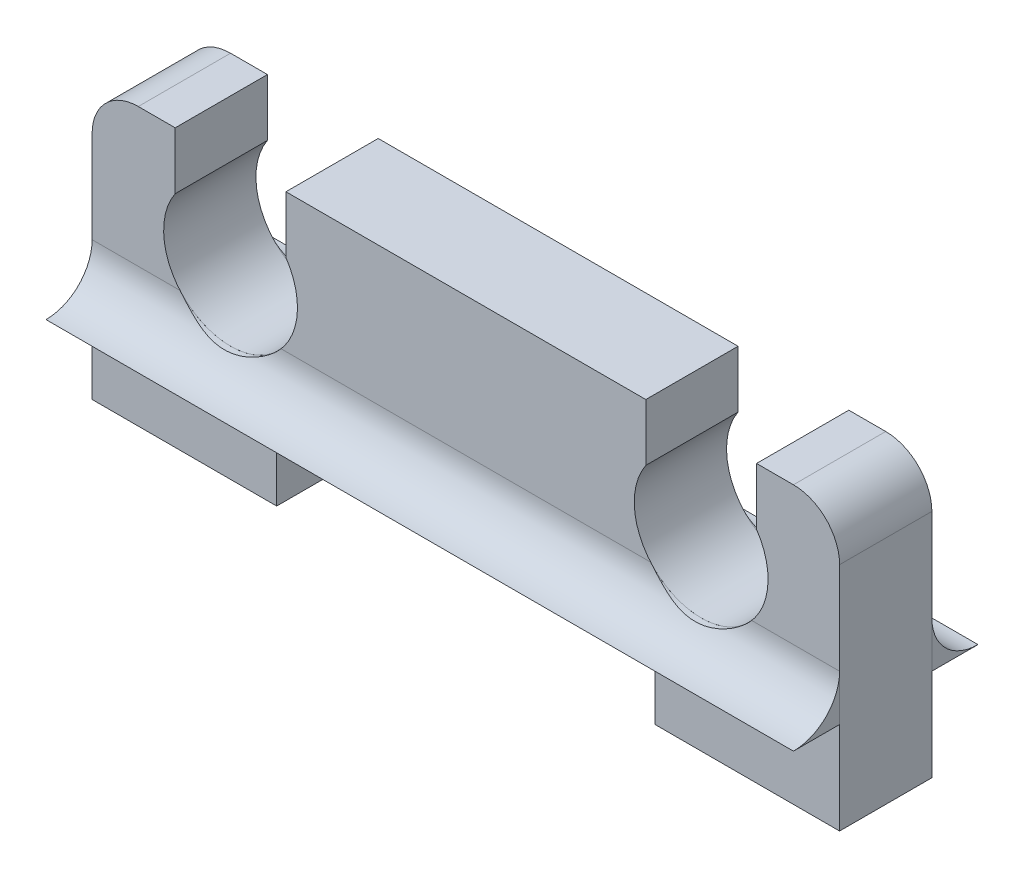
from build123d import *

# Parameters (mm, degrees)
BOSS_EXTRUDE1_DEPTH     = 2
BOSS_EXTRUDE2_DEPTH     = 16.2
BOSS_EXTRUDE2_2_DEPTH   = 16.2
SKETCH3_W               = 4
SKETCH3_H               = 2
CUT_EXTRUDE1_DEPTH      = 4
CUT_EXTRUDE4_START      = -1.236059
SKETCH5_W               = 2.4
SKETCH5_H               = 2
CUT_EXTRUDE4_DEPTH      = 1.236059
SKETCH8_R               = 1.45
CUT_EXTRUDE6_DEPTH      = 3
CUT_EXTRUDE6_DEPTH_BACK = 3


with BuildPart() as part:
    # Sketch1 → Boss-Extrude1 (new body)
    with BuildSketch(Plane.XY):
        with BuildLine():
            Line((4, 8), (8.1, 8))
            Line((8.1, 8), (12.2, 8))
            Line((12.2, 8), (12.2, 7))
            ThreePointArc((12.2, 7), (13.2, 4.5), (14.2, 7))
            Line((14.2, 7), (14.2, 8))
            Line((14.2, 8), (15.2, 8))
            ThreePointArc((15.2, 8), (15.907106781, 7.707106781), (16.2, 7))
            Line((16.2, 7), (16.2, 0))
            Line((16.2, 0), (12.2, 0))
            Line((12.2, 0), (12.2, 4))
            Line((12.2, 4), (4, 4))
            Line((4, 4), (4, 0))
            Line((4, 0), (0, 0))
            Line((0, 0), (0, 7))
            ThreePointArc((0, 7), (0.292893219, 7.707106781), (1, 8))
            Line((1, 8), (2, 8))
            Line((2, 8), (2, 7))
            ThreePointArc((2, 7), (3, 4.5), (4, 7))
            Line((4, 7), (4, 8))
        make_face()
    extrude(amount=BOSS_EXTRUDE1_DEPTH)

    # Sketch3 → Cut-Extrude1 (cut, through all)
    with BuildSketch(Plane.XY.offset(2)):
        with Locations((2, 1)):
            Rectangle(SKETCH3_W, SKETCH3_H)
        with Locations((14.2, 1)):
            Rectangle(SKETCH3_W, SKETCH3_H)
    extrude(amount=-CUT_EXTRUDE1_DEPTH, mode=Mode.SUBTRACT)

    # Sketch5 → Cut-Extrude4 (cut)
    with BuildSketch(Plane(origin=(0, 8, 0), x_dir=(1, 0, 0), z_dir=(0, 1, 0)).offset(CUT_EXTRUDE4_START)):
        with Locations((3, -1)):
            Rectangle(SKETCH5_W, SKETCH5_H)
        with Locations((13.2, -1)):
            Rectangle(SKETCH5_W, SKETCH5_H)
    extrude(amount=CUT_EXTRUDE4_DEPTH, mode=Mode.SUBTRACT)


with BuildPart() as body_2:
    # Sketch2 → Boss-Extrude2 (new body)
    with BuildSketch(Plane.ZY):
        with BuildLine():
            Line((2, 4), (2, 5))
            ThreePointArc((2, 5), (2.292893219, 4.292893219), (3, 4))
            Line((3, 4), (2, 4))
        make_face()
    extrude(amount=-BOSS_EXTRUDE2_DEPTH)


with BuildPart() as body_3:
    # Sketch2 → Boss-Extrude2 2 (new body)
    with BuildSketch(Plane.ZY):
        with BuildLine():
            Line((0, 4), (-1, 4))
            ThreePointArc((-1, 4), (-0.292893219, 4.292893219), (0, 5))
            Line((0, 5), (0, 4))
        make_face()
    extrude(amount=-BOSS_EXTRUDE2_2_DEPTH)


with BuildPart() as cut_extrude6_tool:
    # Sketch8 → Cut-Extrude6 (new body, two sides)
    with BuildSketch(Plane.XY.offset(1)) as cut_extrude6_sk:
        with Locations((3, 5.95)):
            Circle(SKETCH8_R)
        with Locations((13.2, 5.95)):
            Circle(SKETCH8_R)
    extrude(amount=CUT_EXTRUDE6_DEPTH)
    extrude(cut_extrude6_sk.sketch, amount=-CUT_EXTRUDE6_DEPTH_BACK)


with BuildPart() as body_2_1:
    add(body_2.part)

    # Cut-Extrude6: cut by cut_extrude6_tool
    add(cut_extrude6_tool.part, mode=Mode.SUBTRACT)


with BuildPart() as body_3_1:
    add(body_3.part)

    # Cut-Extrude6: cut by cut_extrude6_tool
    add(cut_extrude6_tool.part, mode=Mode.SUBTRACT)


solid = Compound([part.part, body_2_1.part, body_3_1.part])
